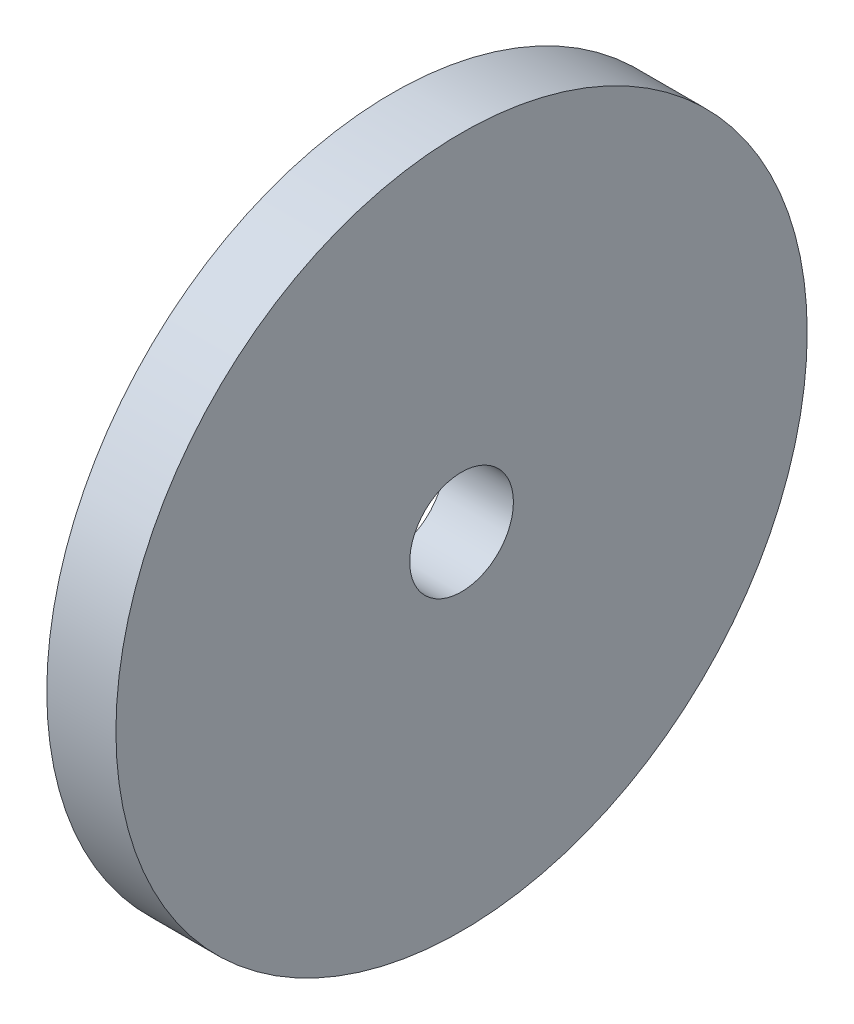
from build123d import *

# Parameters (mm, degrees)
SKETCH1_R           = 10
BOSS_EXTRUDE1_DEPTH = 2
SKETCH2_R           = 1.5
CUT_EXTRUDE1_DEPTH  = 3


with BuildPart() as part:
    # Sketch1 → Boss-Extrude1 (new body)
    with BuildSketch(Plane(origin=(0, 0, 0), x_dir=(0, 0, -1), z_dir=(1, 0, 0))):
        Circle(SKETCH1_R)
    extrude(amount=BOSS_EXTRUDE1_DEPTH)

    # Sketch2 → Cut-Extrude1 (cut, through all)
    with BuildSketch(Plane(origin=(2, 0, 0), x_dir=(0, 0, -1), z_dir=(1, 0, 0))):
        Circle(SKETCH2_R)
    extrude(amount=-CUT_EXTRUDE1_DEPTH, mode=Mode.SUBTRACT)


solid = part.part
